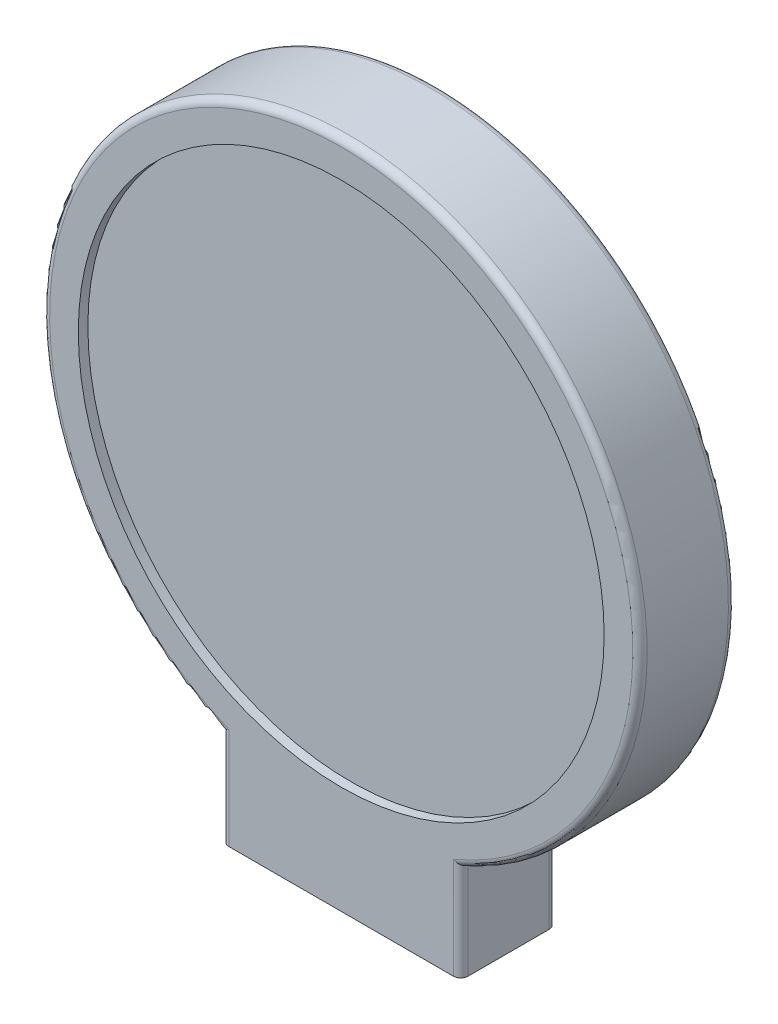
from build123d import *

# Parameters (mm, degrees)
SKETCH2_R           = 110
BOSS_EXTRUDE1_DEPTH = 40
SKETCH5_R           = 110
BOSS_EXTRUDE2_DEPTH = 36
FILLET1_R           = 3
SKETCH6_W           = 80
SKETCH6_H           = 20
CUT_EXTRUDE2_DEPTH  = 30
SKETCH7_W           = 70
SKETCH7_H           = 10
BOSS_EXTRUDE3_DEPTH = 30
SKETCH8_W           = 5
SKETCH8_H           = 30
BOSS_EXTRUDE4_DEPTH = 3


with BuildPart() as part:
    # Sketch2 → Boss-Extrude1 (new body)
    with BuildSketch(Plane.XY):
        with BuildLine():
            Line((-50, 0), (50, 0))
            Line((50, 0), (50, 40.435607626))
            ThreePointArc((50, 40.435607626), (0, 280), (-50, 40.435607626))
            Line((-50, 40.435607626), (-50, 0))
        make_face()
        with Locations((0, 155)):
            Circle(SKETCH2_R, mode=Mode.SUBTRACT)
    extrude(amount=BOSS_EXTRUDE1_DEPTH)

    # Sketch5 → Boss-Extrude2 (add)
    with BuildSketch(Plane(origin=(0, 0, 0), x_dir=(-1, 0, 0), z_dir=(0, 0, -1))):
        with Locations((0, 155)):
            Circle(SKETCH5_R)
    extrude(amount=-BOSS_EXTRUDE2_DEPTH)

    # Fillet1
    fillet1_edges = [part.edges().sort_by_distance(p)[0] for p in [
        (-50, 20.217803813, 40),
        (50, 20.217803813, 40),
        (-50, 20.217803813, 0),
        (0, 280, 0),
        (50, 20.217803813, 0),
        (0, 280, 40),
    ]]
    fillet(fillet1_edges, radius=FILLET1_R)

    # Sketch6 → Cut-Extrude2 (cut)
    with BuildSketch(Plane.XZ):
        with Locations((0, 20)):
            Rectangle(SKETCH6_W, SKETCH6_H)
    extrude(amount=-CUT_EXTRUDE2_DEPTH, mode=Mode.SUBTRACT)

    # Sketch7 → Boss-Extrude3 (add)
    with BuildSketch(Plane.XZ.offset(-30)):
        with Locations((0, 20)):
            Rectangle(SKETCH7_W, SKETCH7_H)
    extrude(amount=BOSS_EXTRUDE3_DEPTH)

    # Sketch8 → Boss-Extrude4 (add)
    with BuildSketch(Plane.XY.offset(25)):
        with Locations((-32.5, 15)):
            Rectangle(SKETCH8_W, SKETCH8_H)
        with Locations((-22.5, 15)):
            Rectangle(SKETCH8_W, SKETCH8_H)
        with Locations((-12.5, 15)):
            Rectangle(SKETCH8_W, SKETCH8_H)
        with Locations((-2.5, 15)):
            Rectangle(SKETCH8_W, SKETCH8_H)
        with Locations((7.5, 15)):
            Rectangle(SKETCH8_W, SKETCH8_H)
        with Locations((17.5, 15)):
            Rectangle(SKETCH8_W, SKETCH8_H)
        with Locations((27.5, 15)):
            Rectangle(SKETCH8_W, SKETCH8_H)
    boss_extrude4 = extrude(amount=BOSS_EXTRUDE4_DEPTH)

    # Mirror2: Boss-Extrude4 across plane
    add(boss_extrude4.mirror(Plane.XY.offset(21.007174775)))


solid = part.part
